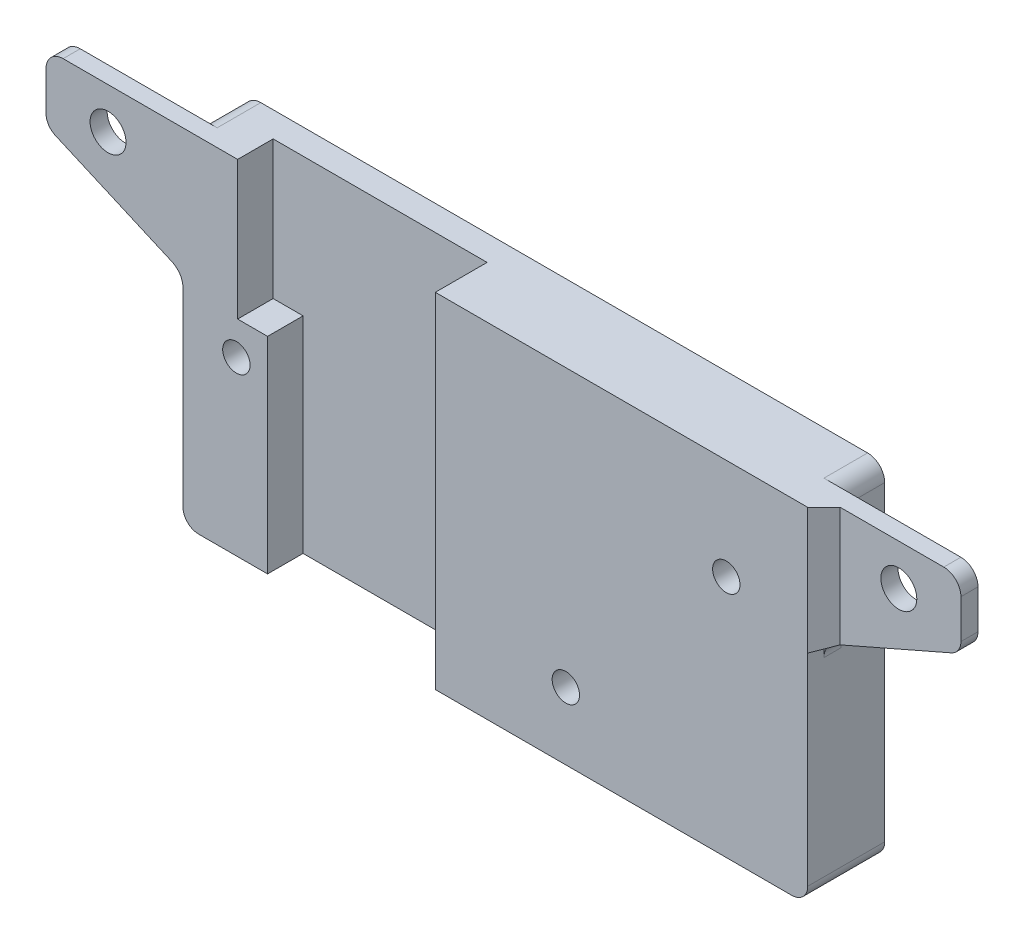
from build123d import *

# Parameters (mm, degrees)
BOSS_EXTRUDE1_DEPTH  = 5.1
SKETCH2_R            = 2.1
BOSS_EXTRUDE2_DEPTH  = 0.9
FILLET1_R            = 2
SKETCH3_R            = 2.1
BOSS_EXTRUDE3_DEPTH  = 1.1
BOSS_EXTRUDE4_DEPTH  = 16.158031
SKETCH5_W            = 25
SKETCH5_H            = 40.2
CUT_EXTRUDE2_DEPTH   = 3.05
SKETCH6_W            = 6
SKETCH6_H            = 24.2
BOSS_EXTRUDE5_DEPTH  = 3.5
CUT_EXTRUDE3_DEPTH   = 16.158031
BOSS_EXTRUDE6_DEPTH  = 3
BOSS_EXTRUDE7_REACH  = 42.2
SKETCH21_R           = 1.6
CUT_EXTRUDE6_DEPTH   = 9
CUT_EXTRUDE7_DEPTH   = 17.15803115
SKETCH23_W           = 1.1
SKETCH23_H           = 16.15803115
BOSS_EXTRUDE9_DEPTH  = 6.39
SKETCH26_W           = 3.5
SKETCH26_H           = 3.05
CUT_EXTRUDE11_DEPTH  = 0.158031
BOSS_EXTRUDE10_DEPTH = 1.1
SKETCH28_R           = 1.6
CUT_EXTRUDE12_DEPTH  = 7.1


with BuildPart() as part:
    # Sketch1 → Boss-Extrude1 (new body)
    with BuildSketch(Plane.XY):
        with BuildLine():
            Line((99.95, 149.85), (25.05, 149.85))
            Line((25.05, 149.85), (25.05, 148))
            Line((25.05, 148), (25.05, 111.5))
            ThreePointArc((25.05, 111.5), (25.591852455, 110.191852455), (26.9, 109.65))
            Line((26.9, 109.65), (98.1, 109.65))
            ThreePointArc((98.1, 109.65), (99.408147545, 110.191852455), (99.95, 111.5))
            Line((99.95, 111.5), (99.95, 148))
            Line((99.95, 148), (99.95, 149.85))
        make_face()
    extrude(amount=BOSS_EXTRUDE1_DEPTH)

    # Sketch2 → Boss-Extrude2 (add)
    with BuildSketch(Plane.XY.offset(5.1)):
        with BuildLine():
            Line((102.1, 149.85), (22.9, 149.85))
            Line((22.9, 149.85), (9.05, 149.85))
            Line((9.05, 149.85), (9.05, 148))
            Line((9.05, 148), (9.05, 143.30803115))
            ThreePointArc((9.05, 143.30803115), (9.351726371, 142.295436082), (10.158485157, 141.61314008))
            Line((10.158485157, 141.61314008), (23.761760493, 135.66170712))
            ThreePointArc((23.761760493, 135.66170712), (24.699345028, 134.868768523), (25.05, 133.69196885))
            Line((25.05, 133.69196885), (25.05, 111.5))
            ThreePointArc((25.05, 111.5), (25.591852455, 110.191852455), (26.9, 109.65))
            Line((26.9, 109.65), (98.1, 109.65))
            ThreePointArc((98.1, 109.65), (99.408147545, 110.191852455), (99.95, 111.5))
            Line((99.95, 111.5), (99.95, 133.69196885))
            ThreePointArc((99.95, 133.69196885), (100.300654972, 134.868768523), (101.238239507, 135.66170712))
            Line((101.238239507, 135.66170712), (114.841514843, 141.61314008))
            ThreePointArc((114.841514843, 141.61314008), (115.648273629, 142.295436082), (115.95, 143.30803115))
            Line((115.95, 143.30803115), (115.95, 148))
            Line((115.95, 148), (115.95, 149.85))
            Line((115.95, 149.85), (102.1, 149.85))
        make_face()
        with Locations((16.3, 145.05)):
            Circle(SKETCH2_R, mode=Mode.SUBTRACT)
        with Locations((108.7, 145.05)):
            Circle(SKETCH2_R, mode=Mode.SUBTRACT)
    extrude(amount=BOSS_EXTRUDE2_DEPTH)

    # Fillet1
    fillet1_edges = [part.edges().sort_by_distance(p)[0] for p in [
        (25.05, 149.85, 2.55),
        (99.95, 149.85, 2.55),
        (115.95, 149.85, 5.55),
        (9.05, 149.85, 5.55),
    ]]
    fillet(fillet1_edges, radius=FILLET1_R)

    # Sketch3 → Boss-Extrude3 (add)
    with BuildSketch(Plane.XY.offset(6)):
        with BuildLine():
            Line((99.95, 133.69196885), (99.95, 149.85))
            Line((99.95, 149.85), (113.95, 149.85))
            ThreePointArc((113.95, 149.85), (115.364213562, 149.264213562), (115.95, 147.85))
            Line((115.95, 147.85), (115.95, 143.30803115))
            ThreePointArc((115.95, 143.30803115), (115.648273629, 142.295436082), (114.841514843, 141.61314008))
            Line((114.841514843, 141.61314008), (101.238239507, 135.66170712))
            ThreePointArc((101.238239507, 135.66170712), (100.300654972, 134.868768523), (99.95, 133.69196885))
        make_face()
        with Locations((108.7, 145.05)):
            Circle(SKETCH3_R, mode=Mode.SUBTRACT)
        with BuildLine():
            Line((11.05, 149.85), (25.05, 149.85))
            Line((25.05, 149.85), (25.05, 133.69196885))
            ThreePointArc((25.05, 133.69196885), (24.699345028, 134.868768523), (23.761760493, 135.66170712))
            Line((23.761760493, 135.66170712), (10.158485157, 141.61314008))
            ThreePointArc((10.158485157, 141.61314008), (9.351726371, 142.295436082), (9.05, 143.30803115))
            Line((9.05, 143.30803115), (9.05, 147.85))
            ThreePointArc((9.05, 147.85), (9.635786438, 149.264213562), (11.05, 149.85))
        make_face()
        with Locations((16.3, 145.05)):
            Circle(SKETCH3_R, mode=Mode.SUBTRACT)
    extrude(amount=BOSS_EXTRUDE3_DEPTH)

    # Sketch4 → Boss-Extrude4 (add)
    with BuildSketch(Plane(origin=(0, 149.85, 0), x_dir=(1, 0, 0), z_dir=(0, 1, 0))):
        Polygon((25.05, -7.1), (27.55, -6), (25.05, -6), align=None)
        Polygon((97.45, -6), (99.95, -7.1), (99.95, -6), align=None)
    extrude(amount=-BOSS_EXTRUDE4_DEPTH)

    # Sketch5 → Cut-Extrude2 (cut)
    with BuildSketch(Plane.XY.offset(6)):
        with Locations((43.94, 129.75)):
            Rectangle(SKETCH5_W, SKETCH5_H)
    extrude(amount=-CUT_EXTRUDE2_DEPTH, mode=Mode.SUBTRACT)

    # Sketch6 → Boss-Extrude5 (add)
    with BuildSketch(Plane(origin=(31.44, 0, 0), x_dir=(0, 0, -1), z_dir=(1, 0, 0))):
        with Locations((-3, 121.75)):
            Rectangle(SKETCH6_W, SKETCH6_H)
    extrude(amount=BOSS_EXTRUDE5_DEPTH)

    # Sketch9 → Cut-Extrude3 (cut)
    with BuildSketch(Plane.XZ.offset(-133.69196885)):
        Polygon((97.45, 6), (99.95, 7.1), (99.95, 6), align=None)
    extrude(amount=-CUT_EXTRUDE3_DEPTH, mode=Mode.SUBTRACT)

    # Sketch10 → Boss-Extrude6 (add)
    with BuildSketch(Plane.XY.offset(6)):
        with BuildLine():
            Line((56.44, 149.85), (56.44, 109.65))
            Line((56.44, 109.65), (98.1, 109.65))
            ThreePointArc((98.1, 109.65), (99.408147545, 110.191852455), (99.95, 111.5))
            Line((99.95, 111.5), (99.95, 149.85))
            Line((99.95, 149.85), (56.44, 149.85))
        make_face()
    extrude(amount=BOSS_EXTRUDE6_DEPTH)

    # Boss-Extrude7: up to this face of the body (flat: up to its plane)
    boss_extrude7_end = Plane(part.part.faces().sort_by_distance((108.039877175, 138.6374236, 6.1))[0])
    # Sketch12 → Boss-Extrude7 (add, up to the picked face)
    with BuildSketch(Plane(origin=(0, 149.85, 0), x_dir=(1, 0, 0), z_dir=(0, 1, 0)), mode=Mode.PRIVATE) as boss_extrude7_sk1:
        Polygon((99.95, -9), (99.95, -7.1), (101.85, -7.1), align=None)
    boss_extrude7_tool1 = split(extrude(boss_extrude7_sk1.sketch, amount=-BOSS_EXTRUDE7_REACH, mode=Mode.PRIVATE), bisect_by=boss_extrude7_end, keep=Keep.BOTH, mode=Mode.PRIVATE)
    add(boss_extrude7_tool1.solids().sort_by_distance((100.583333, 149.85, 7.733333))[0])

    # Sketch21 → Cut-Extrude6 (cut)
    with BuildSketch(Plane.XY.offset(9)):
        with Locations((90.44, 138.06)):
            Circle(SKETCH21_R)
        with Locations((71.69, 117.51)):
            Circle(SKETCH21_R)
    extrude(amount=-CUT_EXTRUDE6_DEPTH, mode=Mode.SUBTRACT)

    # Sketch22 → Cut-Extrude7 (cut, through all)
    with BuildSketch(Plane.XZ.offset(-133.69196885)):
        Polygon((25.05, 7.1), (25.05, 6), (27.55, 6), align=None)
    extrude(amount=-CUT_EXTRUDE7_DEPTH, mode=Mode.SUBTRACT)

    # Sketch23 → Boss-Extrude9 (add)
    with BuildSketch(Plane(origin=(25.05, 0, 0), x_dir=(0, 0, -1), z_dir=(1, 0, 0))):
        with Locations((-6.55, 141.770984425)):
            Rectangle(SKETCH23_W, SKETCH23_H)
    extrude(amount=BOSS_EXTRUDE9_DEPTH)

    # Sketch26 → Cut-Extrude11 (cut)
    with BuildSketch(Plane(origin=(0, 133.85, 0), x_dir=(1, 0, 0), z_dir=(0, 1, 0))):
        with Locations((33.19, -4.475)):
            Rectangle(SKETCH26_W, SKETCH26_H)
    extrude(amount=-CUT_EXTRUDE11_DEPTH, mode=Mode.SUBTRACT)

    # Sketch27 → Boss-Extrude10 (add)
    with BuildSketch(Plane.XY.offset(6)):
        with BuildLine():
            Line((34.94, 109.65), (34.94, 133.69196885))
            Line((34.94, 133.69196885), (25.05, 133.69196885))
            Line((25.05, 133.69196885), (25.05, 111.5))
            ThreePointArc((25.05, 111.5), (25.591852455, 110.191852455), (26.9, 109.65))
            Line((26.9, 109.65), (34.94, 109.65))
        make_face()
    extrude(amount=BOSS_EXTRUDE10_DEPTH)

    # Sketch28 → Cut-Extrude12 (cut)
    with BuildSketch(Plane.XY.offset(7.1)):
        with Locations((31.295, 129.75)):
            Circle(SKETCH28_R)
    extrude(amount=-CUT_EXTRUDE12_DEPTH, mode=Mode.SUBTRACT)


solid = part.part
